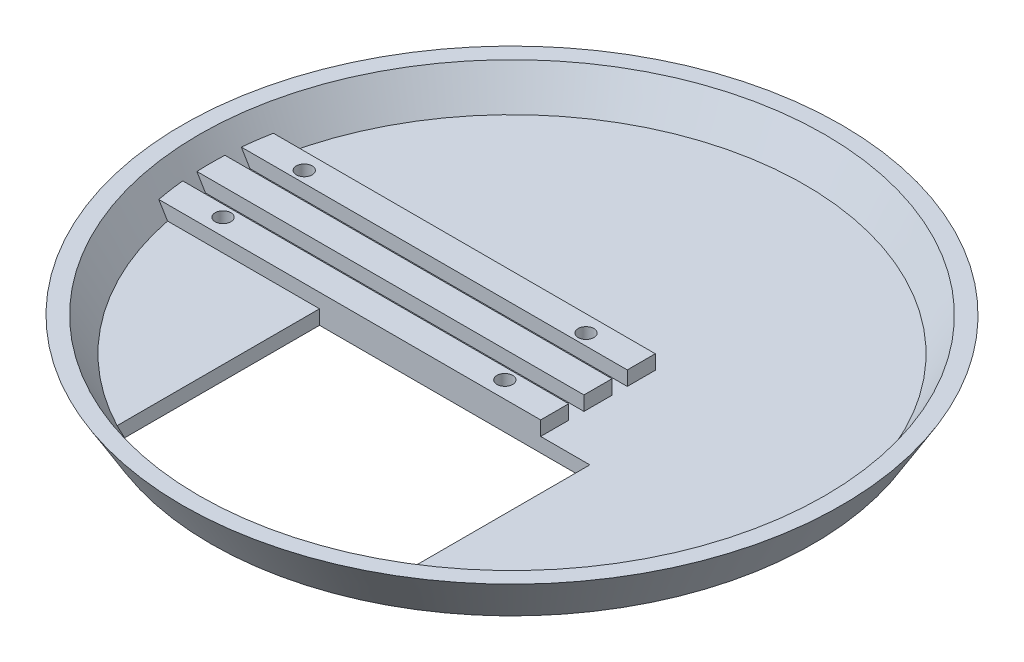
from build123d import *

# Parameters (mm, degrees)
CUT_EXTRUDE1_DEPTH       = 4
SKETCH4_W                = 5.866666667
SKETCH4_H                = 3
SKETCH4_W_2              = 5.866666666
BOSS_EXTRUDE1_DEPTH      = 10
BOSS_EXTRUDE1_DEPTH_BACK = 63.5
SKETCH5_R                = 1.65
CUT_EXTRUDE2_DEPTH       = 11
SKETCH8_W                = 5.866666667
SKETCH8_H                = 3
SKETCH8_W_2              = 5.866666666
BOSS_EXTRUDE3_DEPTH      = 8


with BuildPart() as part:
    # Sketch1 → Revolve1 (revolve)
    with BuildSketch(Plane.XY):
        Polygon((0, 0), (63, 0), (69, 10), (65.501428863, 10), (61.301428863, 3), (0, 3), align=None)
    revolve(axis=Axis((0, 0, 0), (0, 1, 0)))

    # Sketch2 → Cut-Extrude1 (cut, through all)
    with BuildSketch(Plane(origin=(0, 3, 0), x_dir=(1, 0, 0), z_dir=(0, 1, 0))):
        with BuildLine():
            Line((-28.3, -12), (-28.3, -54.378076287))
            ThreePointArc((-28.3, -54.378076287), (0, -61.301428863), (28.3, -54.378076287))
            Line((28.3, -54.378076287), (28.3, -12))
            Line((28.3, -12), (-28.3, -12))
        make_face()
    extrude(amount=-CUT_EXTRUDE1_DEPTH, mode=Mode.SUBTRACT)

    # Sketch4 → Boss-Extrude1 (add, two sides)
    with BuildSketch(Plane(origin=(0, 0, 0), x_dir=(0, 0, -1), z_dir=(1, 0, 0))) as boss_extrude1_sk:
        with Locations((-9.066666666, 4.5)):
            Rectangle(SKETCH4_W, SKETCH4_H)
        with Locations((0, 4.5)):
            Rectangle(SKETCH4_W_2, SKETCH4_H)
        with Locations((9.066666666, 4.5)):
            Rectangle(SKETCH4_W, SKETCH4_H)
    extrude(amount=BOSS_EXTRUDE1_DEPTH)
    extrude(boss_extrude1_sk.sketch, amount=-BOSS_EXTRUDE1_DEPTH_BACK)

    # Sketch5 → Cut-Extrude2 (cut, through all)
    with BuildSketch(Plane(origin=(0, 0, 0), x_dir=(1, 0, 0), z_dir=(0, 1, 0))):
        with Locations((7, -8.5)):
            Circle(SKETCH5_R)
        with Locations((7, 8.5)):
            Circle(SKETCH5_R)
        with Locations((-52, 8.5)):
            Circle(SKETCH5_R)
        with Locations((-52, -8.5)):
            Circle(SKETCH5_R)
    extrude(amount=CUT_EXTRUDE2_DEPTH, mode=Mode.SUBTRACT)

    # Sketch8 → Boss-Extrude3 (add)
    with BuildSketch(Plane(origin=(10, 0, 0), x_dir=(0, 0, -1), z_dir=(1, 0, 0))):
        with Locations((-9.066666666, 4.5)):
            Rectangle(SKETCH8_W, SKETCH8_H)
        with Locations((0, 4.5)):
            Rectangle(SKETCH8_W_2, SKETCH8_H)
        with Locations((9.066666666, 4.5)):
            Rectangle(SKETCH8_W, SKETCH8_H)
    extrude(amount=BOSS_EXTRUDE3_DEPTH)


solid = part.part
